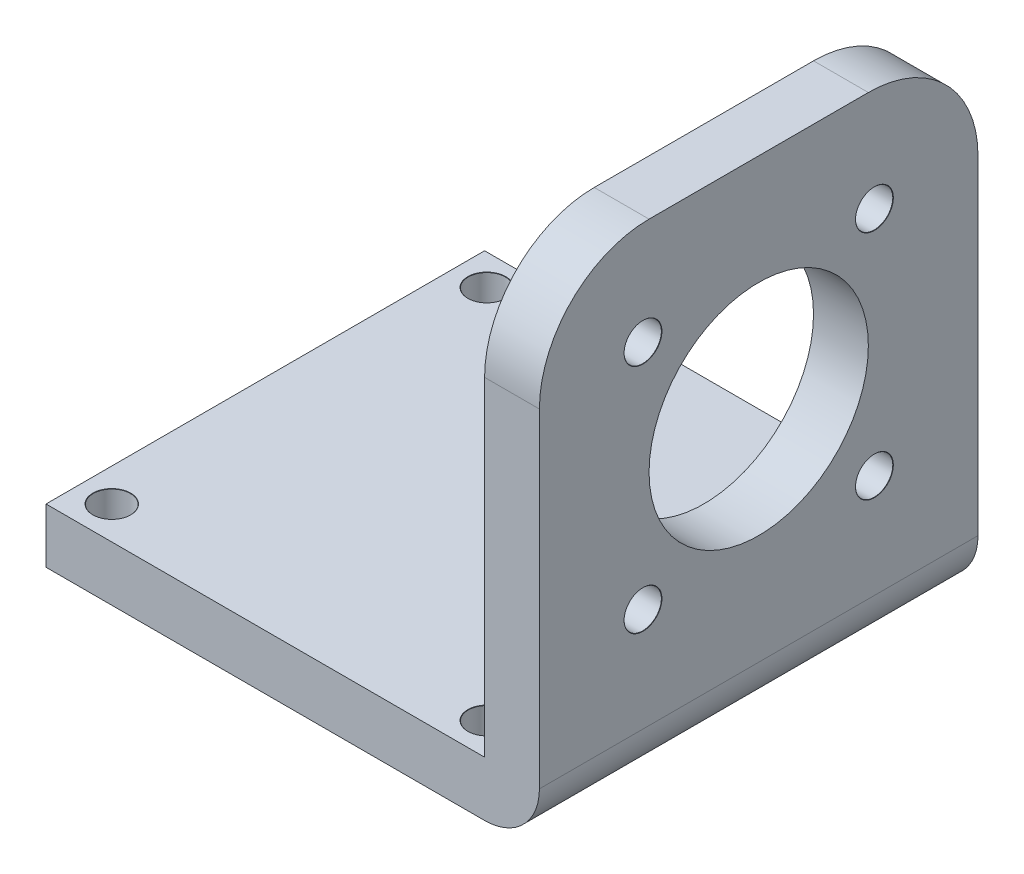
from build123d import *

# Parameters (mm, degrees)
SKETCH1_W                      = 40
SKETCH1_H                      = 40
BOSS_EXTRUDE1_DEPTH            = 5
BOSS_EXTRUDE2_START            = 20
SKETCH2_W                      = 40
SKETCH2_H                      = 45
BOSS_EXTRUDE2_DEPTH            = 5
FILLET1_R                      = 10
FILLET2_R                      = 10
FILLET3_R                      = 5
SKETCH3_R                      = 10
CUT_EXTRUDE1_DEPTH             = 5
M3_CLEARANCE_HOLE1_D           = 3.4
M3_CLEARANCE_HOLE1_CSINK_D     = 3.45
M3_CLEARANCE_HOLE1_CSINK_ANGLE = 90
CIRPATTERN1_COUNT              = 4
M3_CLEARANCE_HOLE2_D           = 3.4
M3_CLEARANCE_HOLE2_CSINK_D     = 3.45
M3_CLEARANCE_HOLE2_CSINK_ANGLE = 90
CIRPATTERN2_COUNT              = 4


with BuildPart() as part:
    # Sketch1 → Boss-Extrude1 (new body)
    with BuildSketch(Plane(origin=(0, 0, 0), x_dir=(1, 0, 0), z_dir=(0, 1, 0))):
        Rectangle(SKETCH1_W, SKETCH1_H)
    extrude(amount=BOSS_EXTRUDE1_DEPTH)

    # Sketch2 → Boss-Extrude2 (add)
    with BuildSketch(Plane(origin=(0, 0, 0), x_dir=(0, 0, -1), z_dir=(1, 0, 0)).offset(BOSS_EXTRUDE2_START)):
        with Locations((0, 22.5)):
            Rectangle(SKETCH2_W, SKETCH2_H)
    extrude(amount=BOSS_EXTRUDE2_DEPTH)

    # Fillet1
    fillet1_edges = [part.edges().sort_by_distance(p)[0] for p in [
        (22.5, 45, 20),
    ]]
    fillet(fillet1_edges, radius=FILLET1_R)

    # Fillet2
    fillet2_edges = [part.edges().sort_by_distance(p)[0] for p in [
        (22.5, 45, -20),
    ]]
    fillet(fillet2_edges, radius=FILLET2_R)

    # Fillet3
    fillet3_edges = [part.edges().sort_by_distance(p)[0] for p in [
        (25, 0, 0),
    ]]
    fillet(fillet3_edges, radius=FILLET3_R)

    # Sketch3 → Cut-Extrude1 (cut)
    with BuildSketch(Plane.ZY.offset(-20)):
        with Locations((0, 25)):
            Circle(SKETCH3_R)
    extrude(amount=-CUT_EXTRUDE1_DEPTH, mode=Mode.SUBTRACT)

    # M3 Clearance Hole1 (through all)
    with Locations(Plane(origin=(25, 0, 0), x_dir=(0, 0, -1), z_dir=(1, 0, 0))):
        with Locations((-10.553493254, 35.553493254)):
            m3_clearance_hole1 = CounterSinkHole(M3_CLEARANCE_HOLE1_D / 2, M3_CLEARANCE_HOLE1_CSINK_D / 2, counter_sink_angle=M3_CLEARANCE_HOLE1_CSINK_ANGLE)

    # CirPattern1: M3 Clearance Hole1 ×4 about axis
    cirpattern1_axis = Axis((0, 25, 0), (1, 0, 0))
    for i in range(1, CIRPATTERN1_COUNT):
        add(m3_clearance_hole1.rotate(cirpattern1_axis, i * 360 / CIRPATTERN1_COUNT), mode=Mode.SUBTRACT)

    # M3 Clearance Hole2 (through all)
    with Locations(Plane(origin=(0, 5, 0), x_dir=(1, 0, 0), z_dir=(0, 1, 0))):
        with Locations((-17, -17)):
            m3_clearance_hole2 = CounterSinkHole(M3_CLEARANCE_HOLE2_D / 2, M3_CLEARANCE_HOLE2_CSINK_D / 2, counter_sink_angle=M3_CLEARANCE_HOLE2_CSINK_ANGLE)

    # CirPattern2: M3 Clearance Hole2 ×4 about axis
    cirpattern2_axis = Axis((0.09990837, 0, -0.09990837), (0, 1, 0))
    for i in range(1, CIRPATTERN2_COUNT):
        add(m3_clearance_hole2.rotate(cirpattern2_axis, i * 360 / CIRPATTERN2_COUNT), mode=Mode.SUBTRACT)


solid = part.part
